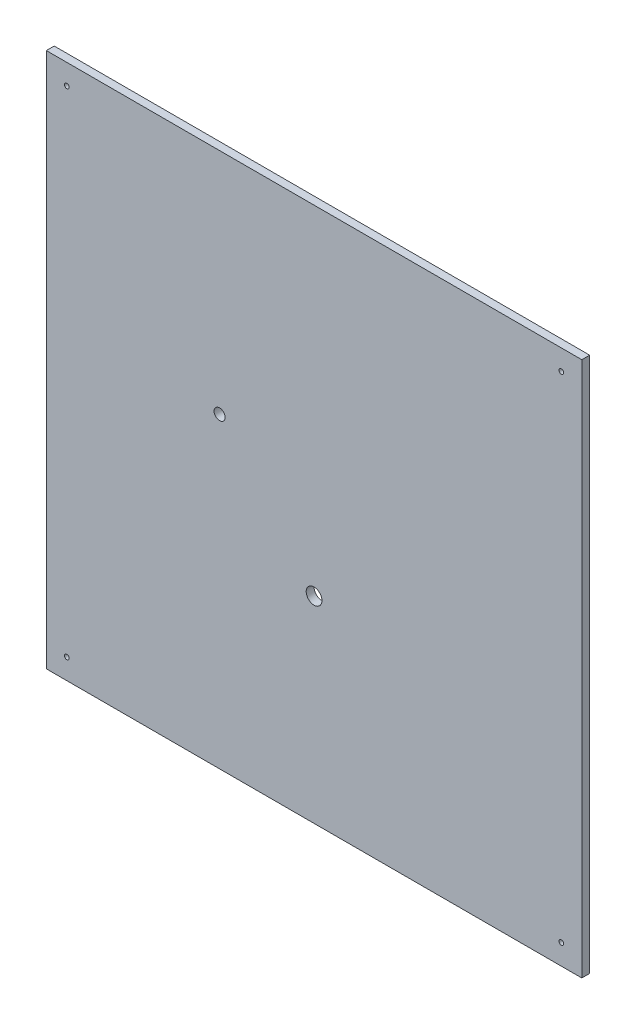
from build123d import *

# Parameters (mm, degrees)
CROQUIS1_W              = 340
CROQUIS1_H              = 340
CROQUIS1_R              = 1.5
CROQUIS1_R_2            = 5
CROQUIS1_R_3            = 3.5
SALIENTE_EXTRUIR1_DEPTH = 5


with BuildPart() as part:
    # Croquis1 → Saliente-Extruir1 (new body)
    with BuildSketch(Plane.XY):
        with Locations((108.94719541, -120.463974458)):
            Rectangle(CROQUIS1_W, CROQUIS1_H)
        with Locations((-48.05280459, -277.463974458)):
            Circle(CROQUIS1_R, mode=Mode.SUBTRACT)
        with Locations((-48.05280459, 36.536025542)):
            Circle(CROQUIS1_R, mode=Mode.SUBTRACT)
        with Locations((265.94719541, -277.463974458)):
            Circle(CROQUIS1_R, mode=Mode.SUBTRACT)
        with Locations((265.94719541, 36.536025542)):
            Circle(CROQUIS1_R, mode=Mode.SUBTRACT)
        with Locations((108.94719541, -165.463974458)):
            Circle(CROQUIS1_R_2, mode=Mode.SUBTRACT)
        with Locations((48.94719541, -95.463974458)):
            Circle(CROQUIS1_R_3, mode=Mode.SUBTRACT)
    extrude(amount=SALIENTE_EXTRUIR1_DEPTH)


solid = part.part
